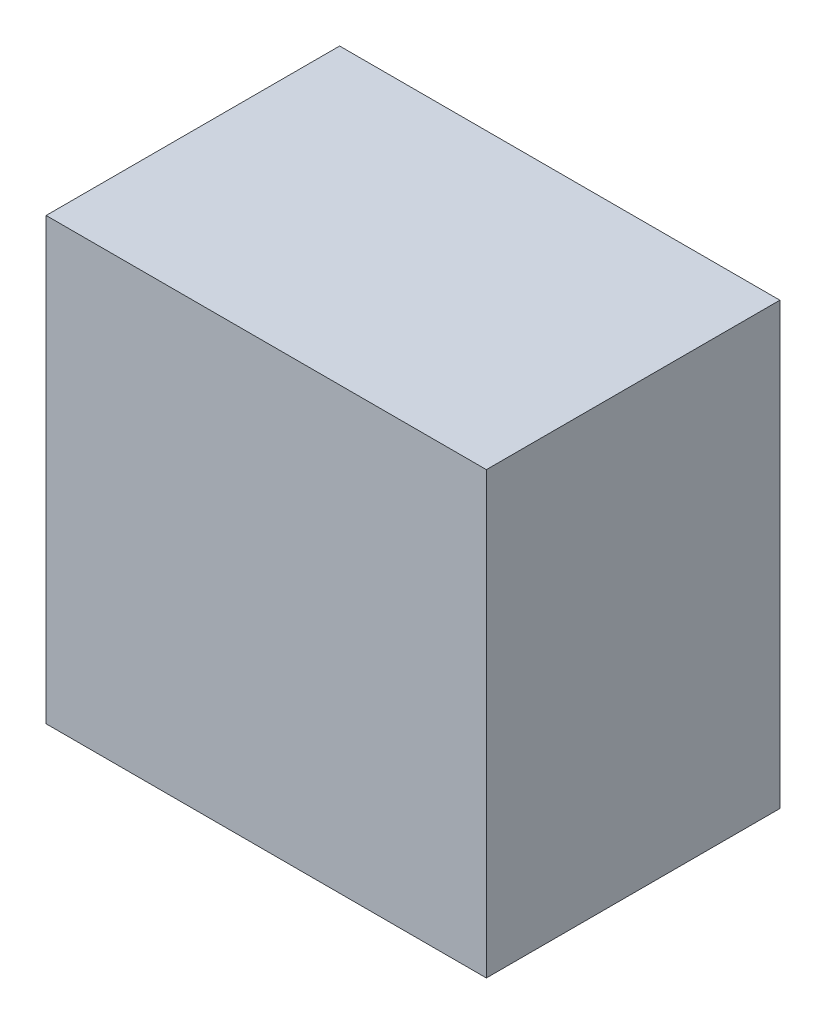
from build123d import *

# Parameters (mm, degrees)
SKETCH1_W           = 30
SKETCH1_H           = 30
BOSS_EXTRUDE1_DEPTH = 20


with BuildPart() as part:
    # Sketch1 → Boss-Extrude1 (new body)
    with BuildSketch(Plane.XY):
        with Locations((15, 15)):
            Rectangle(SKETCH1_W, SKETCH1_H)
    extrude(amount=BOSS_EXTRUDE1_DEPTH)


solid = part.part
